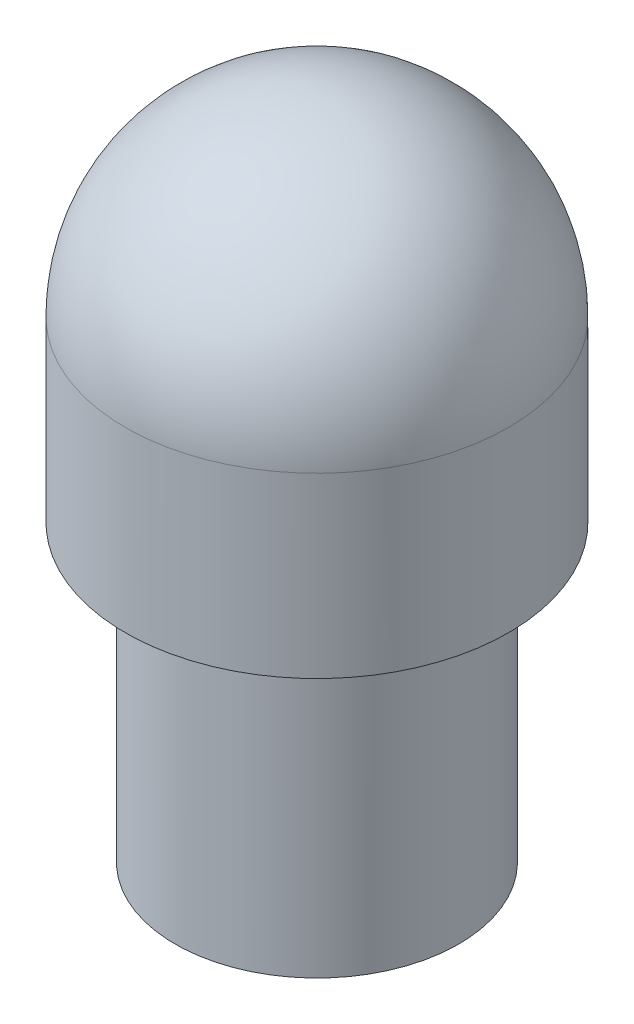
from build123d import *

# Parameters (mm, degrees)
M7X1_0_TAPPED_HOLE1_D     = 6
M7X1_0_TAPPED_HOLE1_DEPTH = 16.002
M7X1_0_TAPPED_HOLE1_TIP   = 1.802581857
SKETCH4_R                 = 3.5
CUT_EXTRUDE1_DEPTH        = 2.5
FILLET1_R                 = 0.762


with BuildPart() as part:
    # Sketch1 → Revolve1 (revolve)
    with BuildSketch(Plane.XY):
        with BuildLine():
            Line((-5.2705, 38.3921), (-5.2705, 33.5026))
            Line((-5.2705, 33.5026), (-3.899, 33.5026))
            Line((-3.899, 33.5026), (-3.899, 25.4))
            Line((-3.899, 25.4), (0, 25.4))
            Line((0, 25.4), (0, 43.6626))
            ThreePointArc((0, 43.6626), (-3.72680629, 42.11890629), (-5.2705, 38.3921))
        make_face()
    revolve(axis=Axis((0, 25.4, 0), (0, 1, 0)))

    # M7x1.0 Tapped Hole1
    with Locations(Plane(origin=(0, 25.4, 0), x_dir=(-1, 0, 0), z_dir=(0, -1, 0))):
        with Locations((0, 0)):
            Hole(M7X1_0_TAPPED_HOLE1_D / 2, depth=M7X1_0_TAPPED_HOLE1_DEPTH)
            with Locations((0, 0, -(M7X1_0_TAPPED_HOLE1_DEPTH + M7X1_0_TAPPED_HOLE1_TIP / 2))):  # 118° drill point
                Cone(0, M7X1_0_TAPPED_HOLE1_D / 2, M7X1_0_TAPPED_HOLE1_TIP, mode=Mode.SUBTRACT)

    # Sketch4 → Cut-Extrude1 (cut)
    with BuildSketch(Plane.XZ.offset(-25.4)):
        Circle(SKETCH4_R)
    extrude(amount=-CUT_EXTRUDE1_DEPTH, mode=Mode.SUBTRACT)

    # Fillet1
    fillet1_edges = [part.edges().sort_by_distance(p)[0] for p in [
        (3.899, 33.5026, 0),
    ]]
    fillet(fillet1_edges, radius=FILLET1_R)


solid = part.part
